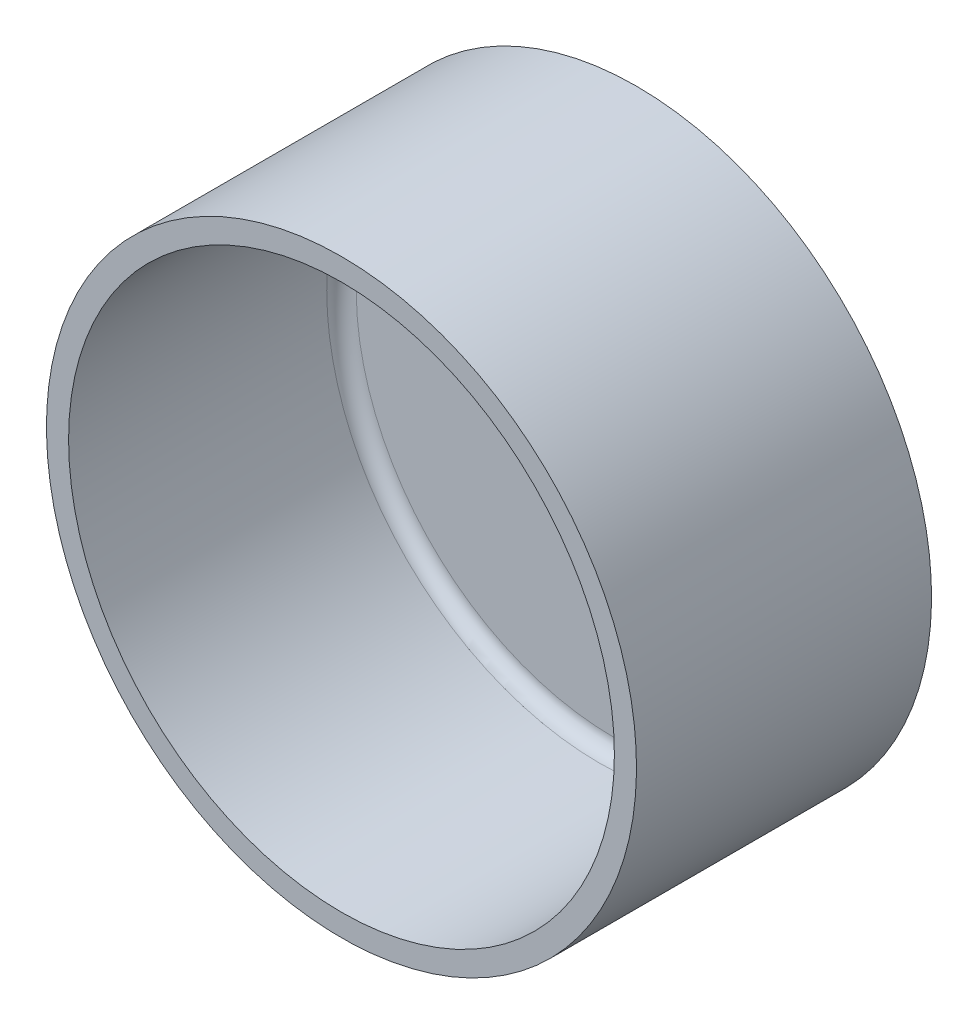
from build123d import *

# Parameters (mm, degrees)
SKETCH1_R           = 10
SKETCH1_R_2         = 2.65
BOSS_EXTRUDE1_DEPTH = 1
SKETCH2_R           = 10
SKETCH4_R           = 20
SKETCH3_R           = 30
SKETCH5_R           = 11.5
SKETCH5_R_2         = 10
BOSS_EXTRUDE2_DEPTH = 1
SKETCH10_R          = 51.016643615
CUT_EXTRUDE2_DEPTH  = 70
FILLET1_R           = 1
SKETCH12_R          = 1
SKETCH12_R_2        = 1.5
CUT_EXTRUDE4_DEPTH  = 10


with BuildPart() as part:
    # Sketch1 → Boss-Extrude1 (new body)
    with BuildSketch(Plane.XY):
        Circle(SKETCH1_R)
        with Locations((0, 6)):
            Circle(SKETCH1_R_2, mode=Mode.SUBTRACT)
        with Locations((5.706339098, 1.854101966)):
            Circle(SKETCH1_R_2, mode=Mode.SUBTRACT)
        with Locations((3.526711514, -4.854101966)):
            Circle(SKETCH1_R_2, mode=Mode.SUBTRACT)
        with Locations((-3.526711514, -4.854101966)):
            Circle(SKETCH1_R_2, mode=Mode.SUBTRACT)
        with Locations((-5.706339098, 1.854101966)):
            Circle(SKETCH1_R_2, mode=Mode.SUBTRACT)
    extrude(amount=BOSS_EXTRUDE1_DEPTH)



with BuildPart() as body_2:
    # Sketch2 → Loft-Thin1 section 0
    with BuildSketch(Plane.XY.offset(1)):
        Circle(SKETCH2_R)
    # Sketch4 → Loft-Thin1 section 1
    with BuildSketch(Plane.XY.offset(15)):
        Circle(SKETCH4_R)
    # Sketch3 → Loft-Thin1 section 2
    with BuildSketch(Plane.XY.offset(45)):
        Circle(SKETCH3_R)
    loft()


with BuildPart() as part_1:
    add(part.part)

    add(body_2.part)  # Boss-Extrude2 merges body 2
    # Sketch5 → Boss-Extrude2 (add)
    with BuildSketch(Plane(origin=(0, 0, 0), x_dir=(-1, 0, 0), z_dir=(0, 0, -1))):
        Circle(SKETCH5_R)
        Circle(SKETCH5_R_2, mode=Mode.SUBTRACT)
    extrude(amount=-BOSS_EXTRUDE2_DEPTH)

    # Sketch10 → Cut-Extrude2 (cut)
    with BuildSketch(Plane.XY):
        Circle(SKETCH10_R)
    extrude(amount=CUT_EXTRUDE2_DEPTH, mode=Mode.SUBTRACT)


with BuildPart() as body_2_2:
    # Sketch8 → Revolve1 (revolve)
    with BuildSketch(Plane(origin=(0, 0, 0), x_dir=(0, 0, -1), z_dir=(1, 0, 0))):
        Polygon((0, 18.5), (18.5, 18.5), (18.5, 0), (20, 0), (20, 20), (0, 20), align=None)
    revolve(axis=Axis((0, 0, -20), (0, 0, 1)))

    # Fillet1
    fillet1_edges = [body_2_2.edges().sort_by_distance(p)[0] for p in [
        (0, -18.5, -18.5),
    ]]
    fillet(fillet1_edges, radius=FILLET1_R)

    # Sketch12 → Cut-Extrude4 (cut)
    with BuildSketch(Plane.XY.offset(-18.5)):
        with Locations((0, 5)):
            Circle(SKETCH12_R)
        with Locations((0, -5)):
            Circle(SKETCH12_R)
        Circle(SKETCH12_R_2)
    extrude(amount=-CUT_EXTRUDE4_DEPTH, mode=Mode.SUBTRACT)


solid = body_2_2.part
